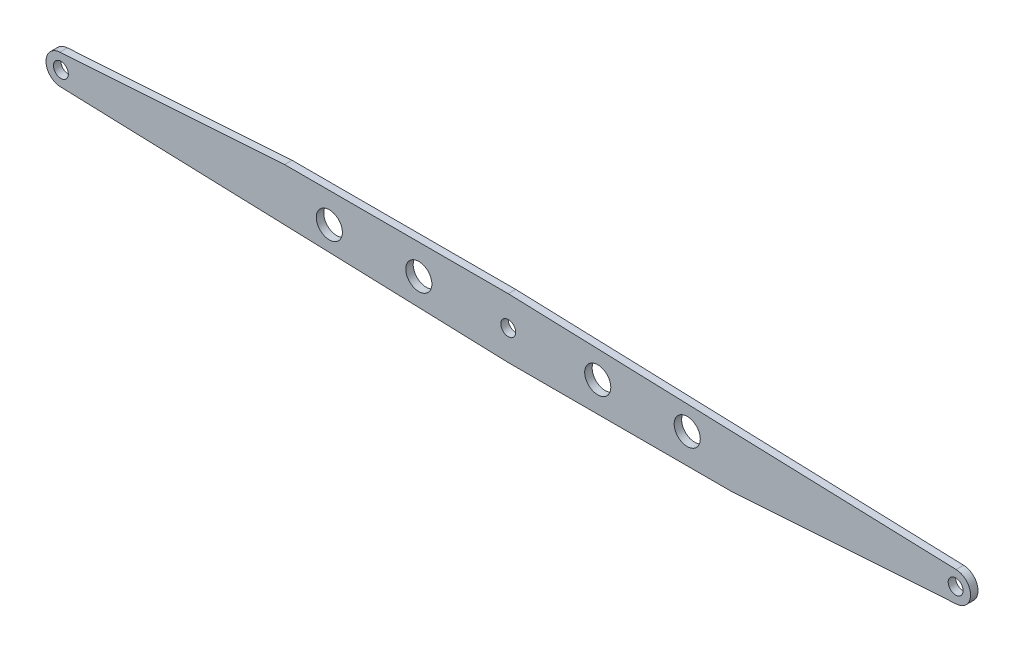
from build123d import *

# Parameters (mm, degrees)
SKETCH1_R           = 10
SKETCH1_R_2         = 17.5
BOSS_EXTRUDE1_DEPTH = 5


with BuildPart() as part:
    # Sketch1 → Boss-Extrude1 (new body, symmetric)
    with BuildSketch(Plane.XY):
        with BuildLine():
            Line((0, 40), (-300, 40))
            Line((-300, 40), (-601.327453078, 19.955898084))
            ThreePointArc((-601.327453078, 19.955898084), (-619.997257899, -0.331174458), (-600.665927363, -19.988910444))
            Line((-600.665927363, -19.988910444), (0, -40))
            Line((0, -40), (300, -40))
            Line((300, -40), (601.327453078, -19.955898084))
            ThreePointArc((601.327453078, -19.955898084), (619.997257899, 0.331174458), (600.665927363, 19.988910444))
            Line((600.665927363, 19.988910444), (0, 40))
        make_face()
        with Locations((-600, 0)):
            Circle(SKETCH1_R, mode=Mode.SUBTRACT)
        with Locations((600, 0)):
            Circle(SKETCH1_R, mode=Mode.SUBTRACT)
        Circle(SKETCH1_R, mode=Mode.SUBTRACT)
        with Locations((-120, 0)):
            Circle(SKETCH1_R_2, mode=Mode.SUBTRACT)
        with Locations((-240, 0)):
            Circle(SKETCH1_R_2, mode=Mode.SUBTRACT)
        with Locations((120, 0)):
            Circle(SKETCH1_R_2, mode=Mode.SUBTRACT)
        with Locations((240, 0)):
            Circle(SKETCH1_R_2, mode=Mode.SUBTRACT)
    extrude(amount=BOSS_EXTRUDE1_DEPTH, both=True)


solid = part.part
